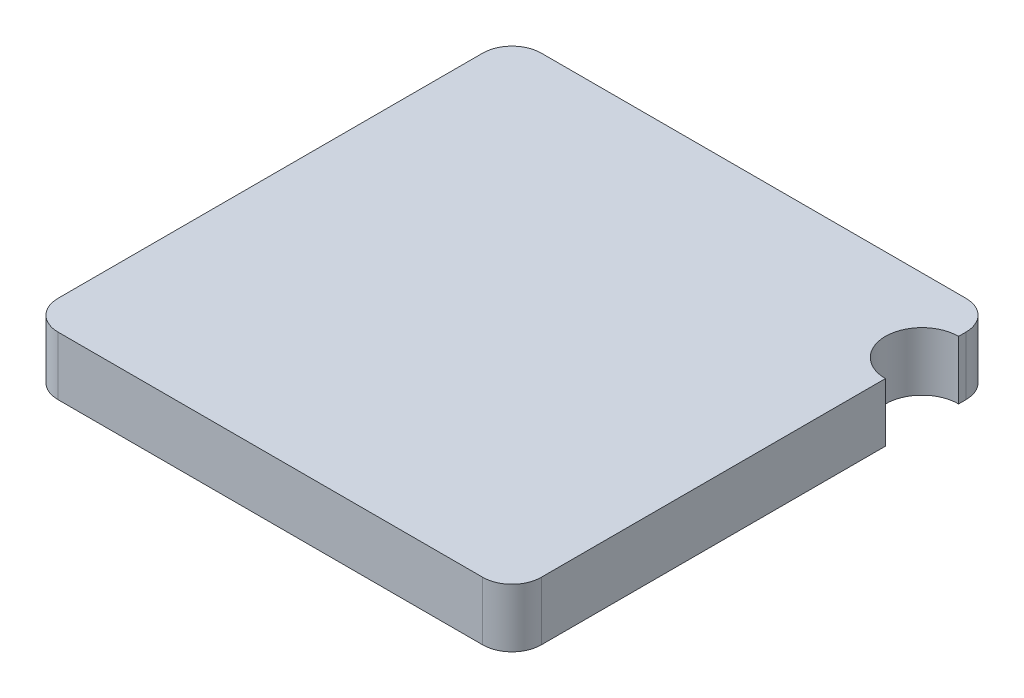
from build123d import *

# Parameters (mm, degrees)
SKETCH1_W           = 1.65
SKETCH1_H           = 1.65
BOSS_EXTRUDE1_DEPTH = 0.2
FILLET1_R           = 0.1
SKETCH2_R           = 0.125
CUT_EXTRUDE1_DEPTH  = 1.2


with BuildPart() as part:
    # Sketch1 → Boss-Extrude1 (new body)
    with BuildSketch(Plane(origin=(0, 0, 0), x_dir=(1, 0, 0), z_dir=(0, 1, 0))):
        Rectangle(SKETCH1_W, SKETCH1_H)
    extrude(amount=BOSS_EXTRUDE1_DEPTH)

    # Fillet1
    fillet1_edges = [part.edges().sort_by_distance(p)[0] for p in [
        (0.825, 0.1, 0.825),
        (-0.825, 0.1, 0.825),
        (-0.825, 0.1, -0.825),
        (0.825, 0.1, -0.825),
    ]]
    fillet(fillet1_edges, radius=FILLET1_R)

    # Sketch2 → Cut-Extrude1 (cut, through all)
    with BuildSketch(Plane(origin=(0, 0.2, 0), x_dir=(1, 0, 0), z_dir=(0, 1, 0))):
        with Locations((0.825, 0.575)):
            Circle(SKETCH2_R)
    extrude(amount=-CUT_EXTRUDE1_DEPTH, mode=Mode.SUBTRACT)


solid = part.part
